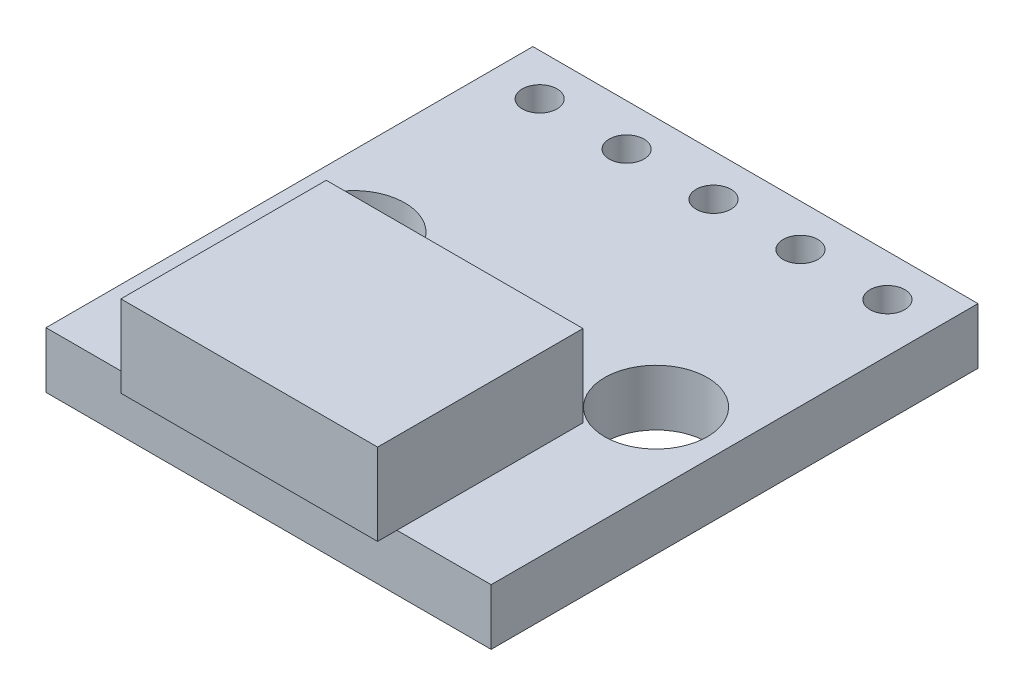
from build123d import *

# Parameters (mm, degrees)
SKETCH1_W           = 13.0048
SKETCH1_H           = 14.224
SKETCH1_R           = 0.508
SKETCH1_R_2         = 1.5
BOSS_EXTRUDE1_DEPTH = 1.6383
SKETCH2_W           = 7.5
SKETCH2_H           = 6
BOSS_EXTRUDE3_DEPTH = 2.3876


with BuildPart() as part:
    # Sketch1 → Boss-Extrude1 (new body)
    with BuildSketch(Plane(origin=(0, 0, 0), x_dir=(1, 0, 0), z_dir=(0, 1, 0))):
        with Locations((6.5024, 7.112)):
            Rectangle(SKETCH1_W, SKETCH1_H)
        with Locations((1.4224, 13)):
            Circle(SKETCH1_R, mode=Mode.SUBTRACT)
        with Locations((3.9624, 13)):
            Circle(SKETCH1_R, mode=Mode.SUBTRACT)
        with Locations((6.5024, 13)):
            Circle(SKETCH1_R, mode=Mode.SUBTRACT)
        with Locations((9.0424, 13)):
            Circle(SKETCH1_R, mode=Mode.SUBTRACT)
        with Locations((11.5824, 13)):
            Circle(SKETCH1_R, mode=Mode.SUBTRACT)
        with Locations((2.0828, 6.9)):
            Circle(SKETCH1_R_2, mode=Mode.SUBTRACT)
        with Locations((10.922, 6.9)):
            Circle(SKETCH1_R_2, mode=Mode.SUBTRACT)
    extrude(amount=BOSS_EXTRUDE1_DEPTH)

    # Sketch2 → Boss-Extrude3 (add)
    with BuildSketch(Plane(origin=(0, 1.6383, 0), x_dir=(1, 0, 0), z_dir=(0, 1, 0))):
        with Locations((6.5024, 2.4356)):
            Rectangle(SKETCH2_W, SKETCH2_H)
    extrude(amount=BOSS_EXTRUDE3_DEPTH)


solid = part.part
